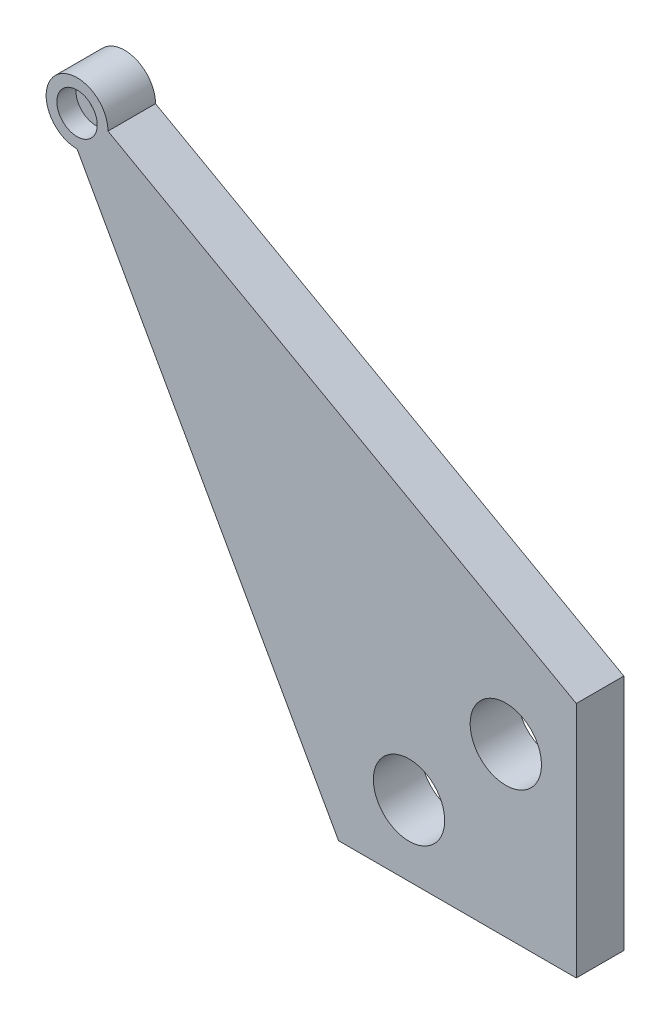
from build123d import *

# Parameters (mm, degrees)
RESSALTO_EXTRUS_O2_DEPTH = 5
ESBO_O4_R                = 4.25
CORTE_EXTRUS_O1_DEPTH    = 4
ESBO_O5_R                = 1.5
CORTE_EXTRUS_O2_DEPTH    = 7
ESBO_O6_R                = 7.5
CORTE_EXTRUS_O3_DEPTH    = 11


with BuildPart() as part:
    # Esboço3 → Ressalto-extrusão2 (new body, symmetric)
    with BuildSketch(Plane.XY):
        with BuildLine():
            Line((0, 50), (98.5, 105))
            ThreePointArc((98.5, 105), (109.596194078, 109.596194078), (105, 98.5))
            Line((105, 98.5), (50, 0))
            Line((50, 0), (0, 0))
            Line((0, 0), (0, 50))
        make_face()
    extrude(amount=RESSALTO_EXTRUS_O2_DEPTH, both=True)

    # Esboço4 → Corte-extrusão1 (cut)
    with BuildSketch(Plane.XY.offset(5)):
        with Locations((105, 105)):
            Circle(ESBO_O4_R)
    extrude(amount=-CORTE_EXTRUS_O1_DEPTH, mode=Mode.SUBTRACT)

    # Esboço5 → Corte-extrusão2 (cut, through all)
    with BuildSketch(Plane.XY.offset(1)):
        with Locations((105, 105)):
            Circle(ESBO_O5_R)
    extrude(amount=-CORTE_EXTRUS_O2_DEPTH, mode=Mode.SUBTRACT)

    # Esboço6 → Corte-extrusão3 (cut, through all)
    with BuildSketch(Plane.XY.offset(5)):
        with Locations((14.825558834, 35.174441166)):
            Circle(ESBO_O6_R)
        with Locations((35.174441166, 14.825558834)):
            Circle(ESBO_O6_R)
    extrude(amount=-CORTE_EXTRUS_O3_DEPTH, mode=Mode.SUBTRACT)


with BuildPart() as body_2:
    # Espelhar1: mirrored copy
    add(part.part.mirror(Plane(origin=(0, 0, 5), x_dir=(0, 0, 1), z_dir=(0, 1, 0))))


with BuildPart() as body_3:
    # Espelhar2: mirrored copy
    add(body_2.part.mirror(Plane(origin=(0, 0, 5), x_dir=(0, 0, 1), z_dir=(1, 0, 0))))


with BuildPart() as body_4:
    # Espelhar2 2: mirrored copy
    add(part.part.mirror(Plane(origin=(0, 0, 5), x_dir=(0, 0, 1), z_dir=(1, 0, 0))))


solid = body_4.part
